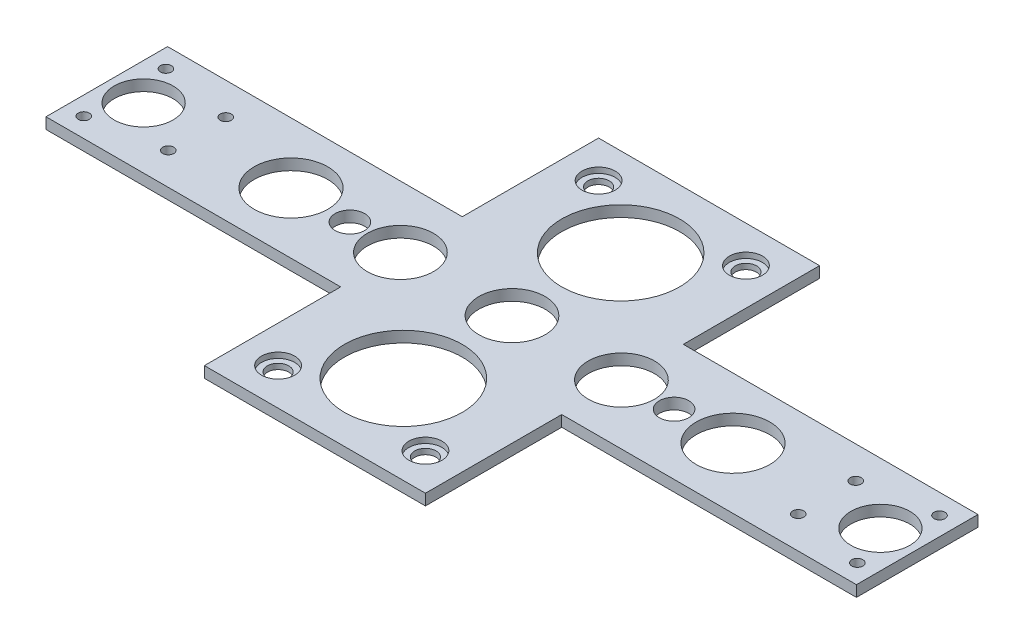
from build123d import *

# Parameters (mm, degrees)
SKETCH_1_R          = 1.5
SKETCH_1_R_2        = 9
SKETCH_1_R_3        = 8
SKETCH_1_R_4        = 10
SKETCH_1_R_5        = 2.9
SKETCH_1_R_6        = 16
SKETCH_1_R_7        = 4
EXTRUDE_1_DEPTH     = 3
SKETCH_2_R          = 4.5
CUT_EXTRUDE_1_DEPTH = 1.5


with BuildPart() as part:
    # 草图1 → 凸台-拉伸1 (new body)
    with BuildSketch(Plane(origin=(0, 0, 0), x_dir=(1, 0, 0), z_dir=(0, 1, 0))):
        Polygon((0, 0), (80, 0), (80, 37), (110, 37), (140, 37), (140, 0), (220, 0), (220, -33), (140, -33), (140, -70), (80, -70), (80, -33), (0, -33), align=None)
        with Locations((5, -27.75)):
            Circle(SKETCH_1_R, mode=Mode.SUBTRACT)
        with Locations((5, -5.45)):
            Circle(SKETCH_1_R, mode=Mode.SUBTRACT)
        with Locations((24.5, -8.7)):
            Circle(SKETCH_1_R, mode=Mode.SUBTRACT)
        with Locations((24.5, -24.3)):
            Circle(SKETCH_1_R, mode=Mode.SUBTRACT)
        with Locations((195.5, -8.7)):
            Circle(SKETCH_1_R, mode=Mode.SUBTRACT)
        with Locations((195.5, -24.3)):
            Circle(SKETCH_1_R, mode=Mode.SUBTRACT)
        with Locations((215, -27.75)):
            Circle(SKETCH_1_R, mode=Mode.SUBTRACT)
        with Locations((215, -5.45)):
            Circle(SKETCH_1_R, mode=Mode.SUBTRACT)
        with Locations((110, -16.5)):
            Circle(SKETCH_1_R_2, mode=Mode.SUBTRACT)
        with Locations((140, -16.796485685)):
            Circle(SKETCH_1_R_2, mode=Mode.SUBTRACT)
        with Locations((10, -16.5)):
            Circle(SKETCH_1_R_3, mode=Mode.SUBTRACT)
        with Locations((210, -16.5)):
            Circle(SKETCH_1_R_3, mode=Mode.SUBTRACT)
        with Locations((170, -16.5)):
            Circle(SKETCH_1_R_4, mode=Mode.SUBTRACT)
        with Locations((80, -16.796485685)):
            Circle(SKETCH_1_R_2, mode=Mode.SUBTRACT)
        with Locations((50, -16.5)):
            Circle(SKETCH_1_R_4, mode=Mode.SUBTRACT)
        with Locations((130, 27)):
            Circle(SKETCH_1_R_5, mode=Mode.SUBTRACT)
        with Locations((90, 27)):
            Circle(SKETCH_1_R_5, mode=Mode.SUBTRACT)
        with Locations((130, -60)):
            Circle(SKETCH_1_R_5, mode=Mode.SUBTRACT)
        with Locations((90, -60)):
            Circle(SKETCH_1_R_5, mode=Mode.SUBTRACT)
        with Locations((110, 13)):
            Circle(SKETCH_1_R_6, mode=Mode.SUBTRACT)
        with Locations((110, -46)):
            Circle(SKETCH_1_R_6, mode=Mode.SUBTRACT)
        with Locations((66, -16.5)):
            Circle(SKETCH_1_R_7, mode=Mode.SUBTRACT)
        with Locations((154, -16.5)):
            Circle(SKETCH_1_R_7, mode=Mode.SUBTRACT)
    extrude(amount=EXTRUDE_1_DEPTH)

    # 草图2 → 切除-拉伸1 (cut)
    with BuildSketch(Plane(origin=(0, 3, 0), x_dir=(1, 0, 0), z_dir=(0, 1, 0))):
        with Locations((90, 27)):
            Circle(SKETCH_2_R)
        with Locations((130, 27)):
            Circle(SKETCH_2_R)
        with Locations((90, -60)):
            Circle(SKETCH_2_R)
        with Locations((130, -60)):
            Circle(SKETCH_2_R)
    extrude(amount=-CUT_EXTRUDE_1_DEPTH, mode=Mode.SUBTRACT)


solid = part.part
